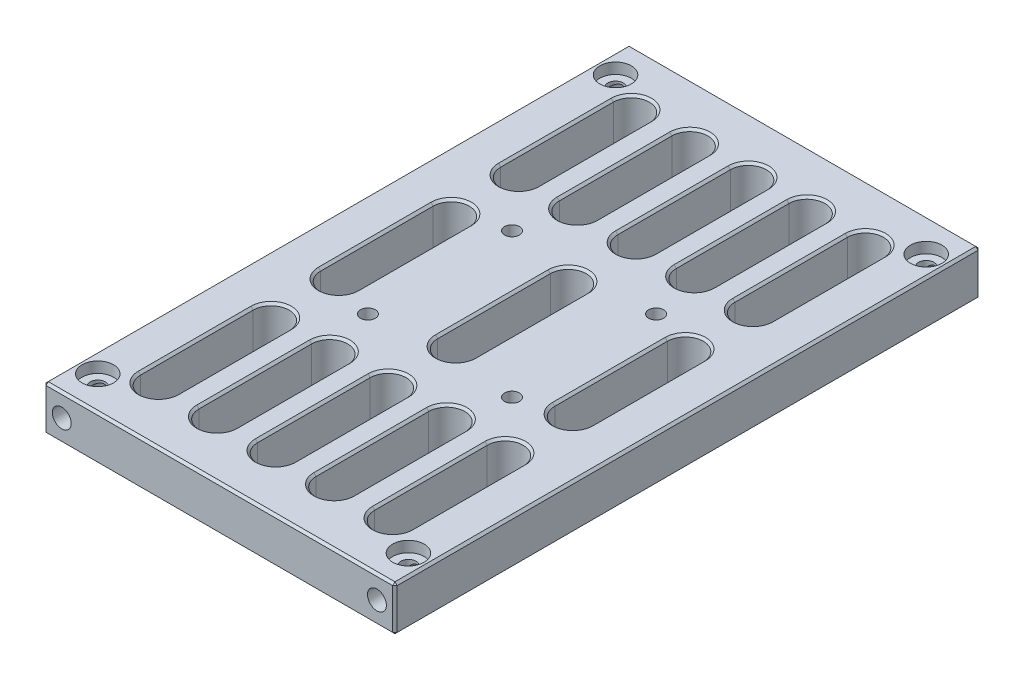
from build123d import *

# Parameters (mm, degrees)
ESQUISSE1_W                                        = 78
ESQUISSE1_H                                        = 10
BOSS_EXTRU_1_DEPTH                                 = 130
TROU_TARAUD_M5X0_81_D                              = 4.2
TROU_TARAUD_M5X0_81_DEPTH                          = 25
TROU_TARAUD_M5X0_81_TIP                            = 1.2618073
TROU_TARAUD_M5X0_82_D                              = 4.2
TROU_TARAUD_M5X0_82_DEPTH                          = 28.2
TROU_TARAUD_M5X0_82_TIP                            = 1.2618073
TROU_TARAUD_M4X0_71_D                              = 3.3
TROU_TARAUD_M4X0_71_DEPTH                          = 10
CHAMBRAGE_POUR_VIS_T_TE_RONDE_BOMB_E_M_D           = 3.4
CHAMBRAGE_POUR_VIS_T_TE_RONDE_BOMB_E_M_CBORE_D     = 7
CHAMBRAGE_POUR_VIS_T_TE_RONDE_BOMB_E_M_CBORE_DEPTH = 2.4
ENL_V_MAT_EXTRU_1_DEPTH                            = 11
CHANFREIN1_SIZE                                    = 0.5
CHANFREIN2_SIZE                                    = 0.5


with BuildPart() as part:
    # Esquisse1 → Boss.-Extru.1 (new body)
    with BuildSketch(Plane.XY):
        with Locations((0, -4.782828283)):
            Rectangle(ESQUISSE1_W, ESQUISSE1_H)
    extrude(amount=BOSS_EXTRU_1_DEPTH)

    # Trou taraudé M5x0.81
    with Locations(Plane(origin=(-35, -4.782828283, 130), x_dir=(1, 0, 0), z_dir=(0, 0, 1))):
        with Locations((0, 0), (70, 0)):
            Hole(TROU_TARAUD_M5X0_81_D / 2, depth=TROU_TARAUD_M5X0_81_DEPTH)
            with Locations((0, 0, -(TROU_TARAUD_M5X0_81_DEPTH + TROU_TARAUD_M5X0_81_TIP / 2))):  # 118° drill point
                Cone(0, TROU_TARAUD_M5X0_81_D / 2, TROU_TARAUD_M5X0_81_TIP, mode=Mode.SUBTRACT)

    # Trou taraudé M5x0.82
    with Locations(Plane(origin=(0, 0, 0), x_dir=(-1, 0, 0), z_dir=(0, 0, -1))):
        with Locations((-35, -4.782828283), (35, -4.782828283)):
            Hole(TROU_TARAUD_M5X0_82_D / 2, depth=TROU_TARAUD_M5X0_82_DEPTH)
            with Locations((0, 0, -(TROU_TARAUD_M5X0_82_DEPTH + TROU_TARAUD_M5X0_82_TIP / 2))):  # 118° drill point
                Cone(0, TROU_TARAUD_M5X0_82_D / 2, TROU_TARAUD_M5X0_82_TIP, mode=Mode.SUBTRACT)

    # Trou taraudé M4x0.71
    with Locations(Plane(origin=(16, 0.217171717, 81), x_dir=(0, 0, 1), z_dir=(0, 1, 0))):
        with Locations((0, 0), (-32, 0), (-32, -32), (0, -32)):
            Hole(TROU_TARAUD_M4X0_71_D / 2, depth=TROU_TARAUD_M4X0_71_DEPTH)

    # Chambrage pour vis à tête ronde bombée M31 (through all)
    with Locations(Plane(origin=(0, 0.217171717, 0), x_dir=(1, 0, 0), z_dir=(0, 1, 0))):
        with Locations((-34.5, -7.5), (34.5, -7.5), (34.5, -122.5), (-34.5, -122.5)):
            CounterBoreHole(CHAMBRAGE_POUR_VIS_T_TE_RONDE_BOMB_E_M_D / 2, CHAMBRAGE_POUR_VIS_T_TE_RONDE_BOMB_E_M_CBORE_D / 2, CHAMBRAGE_POUR_VIS_T_TE_RONDE_BOMB_E_M_CBORE_DEPTH)

    # Esquisse11 → Enlèv. mat.-Extru.1 (cut, through all)
    with BuildSketch(Plane(origin=(0, -9.782828283, 0), x_dir=(-1, 0, 0), z_dir=(0, -1, 0))):
        with BuildLine():
            Line((-30, -117.5), (-30, -92.5))
            ThreePointArc((-30, -92.5), (-26, -88.5), (-22, -92.5))
            Line((-22, -92.5), (-22, -117.5))
            ThreePointArc((-22, -117.5), (-26, -121.5), (-30, -117.5))
        make_face()
        with BuildLine():
            Line((-17, -117.5), (-17, -92.5))
            ThreePointArc((-17, -92.5), (-13, -88.5), (-9, -92.5))
            Line((-9, -92.5), (-9, -117.5))
            ThreePointArc((-9, -117.5), (-13, -121.5), (-17, -117.5))
        make_face()
        with BuildLine():
            Line((-4, -117.5), (-4, -92.5))
            ThreePointArc((-4, -92.5), (0, -88.5), (4, -92.5))
            Line((4, -92.5), (4, -117.5))
            ThreePointArc((4, -117.5), (0, -121.5), (-4, -117.5))
        make_face()
        with BuildLine():
            Line((9, -117.5), (9, -92.5))
            ThreePointArc((9, -92.5), (13, -88.5), (17, -92.5))
            Line((17, -92.5), (17, -117.5))
            ThreePointArc((17, -117.5), (13, -121.5), (9, -117.5))
        make_face()
        with BuildLine():
            Line((22, -117.5), (22, -92.5))
            ThreePointArc((22, -92.5), (26, -88.5), (30, -92.5))
            Line((30, -92.5), (30, -117.5))
            ThreePointArc((30, -117.5), (26, -121.5), (22, -117.5))
        make_face()
        with BuildLine():
            Line((-30, -77.5), (-30, -52.5))
            ThreePointArc((-30, -52.5), (-26, -48.5), (-22, -52.5))
            Line((-22, -52.5), (-22, -77.5))
            ThreePointArc((-22, -77.5), (-26, -81.5), (-30, -77.5))
        make_face()
        with BuildLine():
            Line((-4, -77.5), (-4, -52.5))
            ThreePointArc((-4, -52.5), (0, -48.5), (4, -52.5))
            Line((4, -52.5), (4, -77.5))
            ThreePointArc((4, -77.5), (0, -81.5), (-4, -77.5))
        make_face()
        with BuildLine():
            Line((22, -77.5), (22, -52.5))
            ThreePointArc((22, -52.5), (26, -48.5), (30, -52.5))
            Line((30, -52.5), (30, -77.5))
            ThreePointArc((30, -77.5), (26, -81.5), (22, -77.5))
        make_face()
        with BuildLine():
            Line((-30, -37.5), (-30, -12.5))
            ThreePointArc((-30, -12.5), (-26, -8.5), (-22, -12.5))
            Line((-22, -12.5), (-22, -37.5))
            ThreePointArc((-22, -37.5), (-26, -41.5), (-30, -37.5))
        make_face()
        with BuildLine():
            Line((-17, -37.5), (-17, -12.5))
            ThreePointArc((-17, -12.5), (-13, -8.5), (-9, -12.5))
            Line((-9, -12.5), (-9, -37.5))
            ThreePointArc((-9, -37.5), (-13, -41.5), (-17, -37.5))
        make_face()
        with BuildLine():
            Line((-4, -37.5), (-4, -12.5))
            ThreePointArc((-4, -12.5), (0, -8.5), (4, -12.5))
            Line((4, -12.5), (4, -37.5))
            ThreePointArc((4, -37.5), (0, -41.5), (-4, -37.5))
        make_face()
        with BuildLine():
            Line((9, -37.5), (9, -12.5))
            ThreePointArc((9, -12.5), (13, -8.5), (17, -12.5))
            Line((17, -12.5), (17, -37.5))
            ThreePointArc((17, -37.5), (13, -41.5), (9, -37.5))
        make_face()
        with BuildLine():
            Line((22, -37.5), (22, -12.5))
            ThreePointArc((22, -12.5), (26, -8.5), (30, -12.5))
            Line((30, -12.5), (30, -37.5))
            ThreePointArc((30, -37.5), (26, -41.5), (22, -37.5))
        make_face()
    extrude(amount=-ENL_V_MAT_EXTRU_1_DEPTH, mode=Mode.SUBTRACT)

    # Chanfrein1
    chanfrein1_edges = [part.edges().sort_by_distance(p)[0] for p in [
        (39, -4.782828283, 130),
        (0, 0.217171717, 130),
        (-39, -4.782828283, 130),
        (0, 0.217171717, 0),
        (39, -4.782828283, 0),
        (0, -9.782828283, 0),
        (-39, -4.782828283, 0),
        (-39, 0.217171717, 65),
        (39, 0.217171717, 65),
        (39, -9.782828283, 65),
        (-39, -9.782828283, 65),
        (0, -9.782828283, 130),
    ]]
    chamfer(chanfrein1_edges, length=CHANFREIN1_SIZE)

    # Chanfrein2
    chanfrein2_edges = [part.edges().sort_by_distance(p)[0] for p in [
        (13, 0.217171717, 121.5),
        (17, 0.217171717, 105),
        (13, 0.217171717, 88.5),
        (9, 0.217171717, 105),
        (13, -9.782828283, 121.5),
        (9, -9.782828283, 105),
        (13, -9.782828283, 88.5),
        (17, -9.782828283, 105),
        (0, 0.217171717, 121.5),
        (4, 0.217171717, 105),
        (0, 0.217171717, 88.5),
        (-4, 0.217171717, 105),
        (0, -9.782828283, 121.5),
        (-4, -9.782828283, 105),
        (0, -9.782828283, 88.5),
        (4, -9.782828283, 105),
        (-13, 0.217171717, 121.5),
        (-9, 0.217171717, 105),
        (-13, 0.217171717, 88.5),
        (-17, 0.217171717, 105),
        (-13, -9.782828283, 121.5),
        (-17, -9.782828283, 105),
        (-13, -9.782828283, 88.5),
        (-9, -9.782828283, 105),
        (-26, 0.217171717, 121.5),
        (-22, 0.217171717, 105),
        (-26, 0.217171717, 88.5),
        (-30, 0.217171717, 105),
        (-26, -9.782828283, 121.5),
        (-30, -9.782828283, 105),
        (-26, -9.782828283, 88.5),
        (-22, -9.782828283, 105),
        (26, 0.217171717, 41.5),
        (30, 0.217171717, 25),
        (26, 0.217171717, 8.5),
        (22, 0.217171717, 25),
        (26, -9.782828283, 41.5),
        (22, -9.782828283, 25),
        (26, -9.782828283, 8.5),
        (30, -9.782828283, 25),
        (-26, 0.217171717, 81.5),
        (-22, 0.217171717, 65),
        (-26, 0.217171717, 48.5),
        (-30, 0.217171717, 65),
        (-26, -9.782828283, 81.5),
        (-30, -9.782828283, 65),
        (-26, -9.782828283, 48.5),
        (-22, -9.782828283, 65),
        (0, 0.217171717, 81.5),
        (4, 0.217171717, 65),
        (0, 0.217171717, 48.5),
        (-4, 0.217171717, 65),
        (0, -9.782828283, 81.5),
        (-4, -9.782828283, 65),
        (0, -9.782828283, 48.5),
        (4, -9.782828283, 65),
        (26, 0.217171717, 81.5),
        (30, 0.217171717, 65),
        (26, 0.217171717, 48.5),
        (22, 0.217171717, 65),
        (26, -9.782828283, 81.5),
        (22, -9.782828283, 65),
        (26, -9.782828283, 48.5),
        (30, -9.782828283, 65),
        (13, 0.217171717, 41.5),
        (17, 0.217171717, 25),
        (13, 0.217171717, 8.5),
        (9, 0.217171717, 25),
        (13, -9.782828283, 41.5),
        (9, -9.782828283, 25),
        (13, -9.782828283, 8.5),
        (17, -9.782828283, 25),
        (0, 0.217171717, 41.5),
        (4, 0.217171717, 25),
        (0, 0.217171717, 8.5),
        (-4, 0.217171717, 25),
        (0, -9.782828283, 41.5),
        (-4, -9.782828283, 25),
        (0, -9.782828283, 8.5),
        (4, -9.782828283, 25),
        (-13, 0.217171717, 41.5),
        (-9, 0.217171717, 25),
        (-13, 0.217171717, 8.5),
        (-17, 0.217171717, 25),
        (-13, -9.782828283, 41.5),
        (-17, -9.782828283, 25),
        (-13, -9.782828283, 8.5),
        (-9, -9.782828283, 25),
        (-26, 0.217171717, 41.5),
        (-22, 0.217171717, 25),
        (-26, 0.217171717, 8.5),
        (-30, 0.217171717, 25),
        (-26, -9.782828283, 41.5),
        (-30, -9.782828283, 25),
        (-26, -9.782828283, 8.5),
        (-22, -9.782828283, 25),
        (26, 0.217171717, 121.5),
        (30, 0.217171717, 105),
        (26, 0.217171717, 88.5),
        (22, 0.217171717, 105),
        (26, -9.782828283, 121.5),
        (22, -9.782828283, 105),
        (26, -9.782828283, 88.5),
        (30, -9.782828283, 105),
    ]]
    chamfer(chanfrein2_edges, length=CHANFREIN2_SIZE)


solid = part.part
